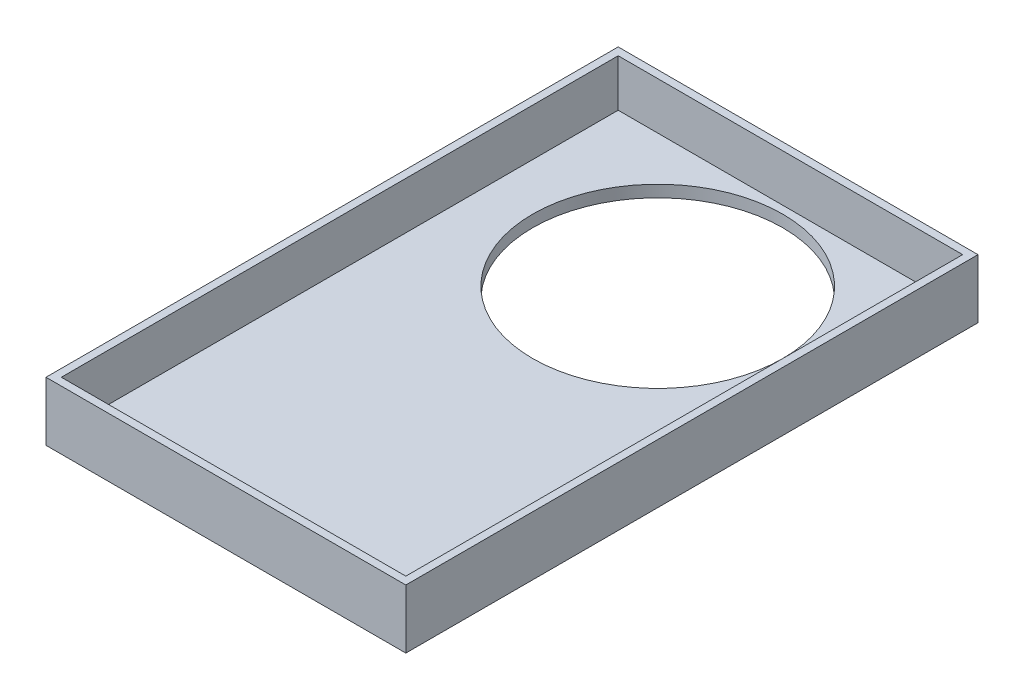
from build123d import *

# Parameters (mm, degrees)
SKETCH1_W           = 61.4
SKETCH1_H           = 48.5
SKETCH1_W_2         = 28.5
SKETCH1_H_2         = 46.5
SKETCH1_W_3         = 28.9
SKETCH1_H_3         = 46.9
BOSS_EXTRUDE1_DEPTH = 35.7
SKETCH2_W           = 29.9
SKETCH2_H           = 48.5
CUT_EXTRUDE1_DEPTH  = 36.7
SKETCH3_W           = 29.2
SKETCH3_H           = 47.2
CUT_EXTRUDE2_DEPTH  = 36.7
SKETCH4_W           = 29.2
SKETCH4_H           = 47.2
SKETCH4_R           = 10.6
BOSS_EXTRUDE2_DEPTH = 1
SKETCH6_W           = 1
SKETCH6_H           = 48.5
CUT_EXTRUDE3_DEPTH  = 36.7
SKETCH7_W           = 30.5
SKETCH7_H           = 30.7
CUT_EXTRUDE4_DEPTH  = 49.5


with BuildPart() as part:
    # Sketch1 → Boss-Extrude1 (new body)
    with BuildSketch(Plane(origin=(0, 0, 0), x_dir=(1, 0, 0), z_dir=(0, 1, 0))):
        with Locations((15.45, -10.593857338)):
            Rectangle(SKETCH1_W, SKETCH1_H)
        with Locations((0, -10.593857338)):
            Rectangle(SKETCH1_W_2, SKETCH1_H_2, mode=Mode.SUBTRACT)
        with Locations((29.7, -10.593857338)):
            Rectangle(SKETCH1_W_3, SKETCH1_H_3, mode=Mode.SUBTRACT)
    extrude(amount=BOSS_EXTRUDE1_DEPTH)

    # Sketch2 → Cut-Extrude1 (cut, through all)
    with BuildSketch(Plane(origin=(0, 35.7, 0), x_dir=(1, 0, 0), z_dir=(0, 1, 0))):
        with Locations((31.2, -10.593857338)):
            Rectangle(SKETCH2_W, SKETCH2_H)
    extrude(amount=-CUT_EXTRUDE1_DEPTH, mode=Mode.SUBTRACT)

    # Sketch3 → Cut-Extrude2 (cut, through all)
    with BuildSketch(Plane(origin=(0, 35.7, 0), x_dir=(1, 0, 0), z_dir=(0, 1, 0))):
        with Locations((0, -10.593857338)):
            Rectangle(SKETCH3_W, SKETCH3_H)
    extrude(amount=-CUT_EXTRUDE2_DEPTH, mode=Mode.SUBTRACT)

    # Sketch4 → Boss-Extrude2 (add)
    with BuildSketch(Plane(origin=(0, 0, 0), x_dir=(1, 0, 0), z_dir=(0, 1, 0))):
        with Locations((0, -10.593857338)):
            Rectangle(SKETCH4_W, SKETCH4_H)
        with Locations((0, 1.756142662)):
            Circle(SKETCH4_R, mode=Mode.SUBTRACT)
    extrude(amount=BOSS_EXTRUDE2_DEPTH)

    # Sketch6 → Cut-Extrude3 (cut, through all)
    with BuildSketch(Plane(origin=(0, 35.7, 0), x_dir=(1, 0, 0), z_dir=(0, 1, 0))):
        with Locations((15.75, -10.593857338)):
            Rectangle(SKETCH6_W, SKETCH6_H)
    extrude(amount=-CUT_EXTRUDE3_DEPTH, mode=Mode.SUBTRACT)

    # Sketch7 → Cut-Extrude4 (cut, through all)
    with BuildSketch(Plane.XY.offset(34.843857338)):
        with Locations((0, 20.35)):
            Rectangle(SKETCH7_W, SKETCH7_H)
    extrude(amount=-CUT_EXTRUDE4_DEPTH, mode=Mode.SUBTRACT)


solid = part.part
